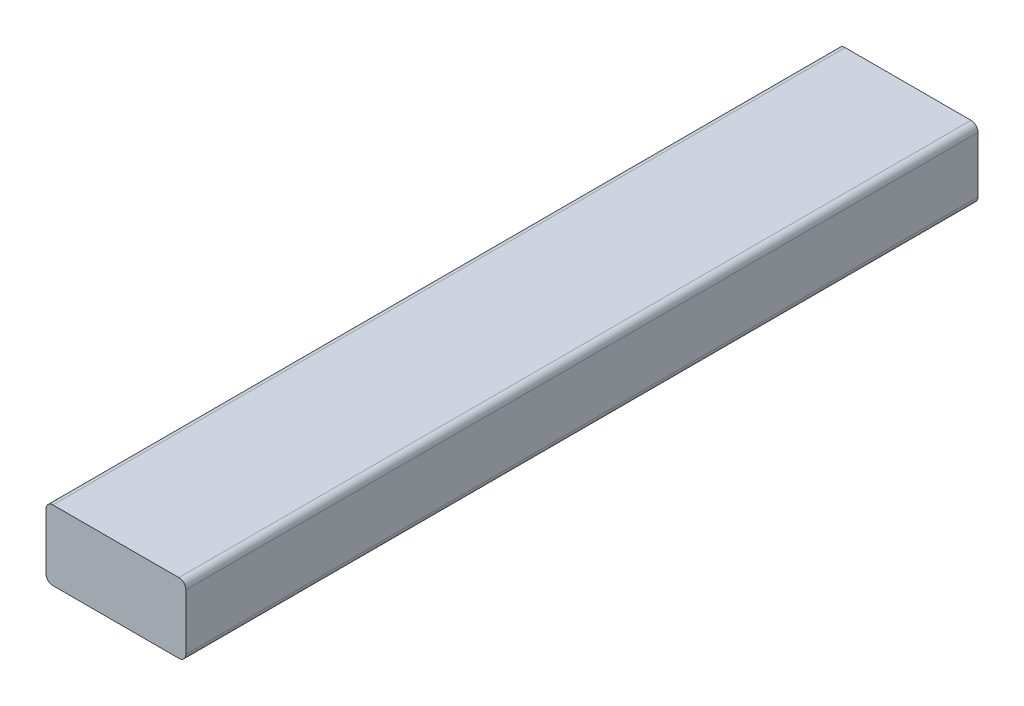
from build123d import *

# Parameters (mm, degrees)
SKETCH2_W           = 101.6
SKETCH2_H           = 50.8
BOSS_EXTRUDE1_DEPTH = 575.4
FILLET1_R           = 5.08


with BuildPart() as part:
    # Sketch2 → Boss-Extrude1 (new body)
    with BuildSketch(Plane(origin=(0, 0, 287.7), x_dir=(-1, 0, 0), z_dir=(0, 0, -1))):
        with Locations((-2663.5, 12.7)):
            Rectangle(SKETCH2_W, SKETCH2_H)
    extrude(amount=BOSS_EXTRUDE1_DEPTH)

    # Fillet1
    fillet1_edges = [part.edges().sort_by_distance(p)[0] for p in [
        (2714.3, 38.1, 0),
        (2612.7, 38.1, 0),
        (2612.7, -12.7, 0),
        (2714.3, -12.7, 0),
    ]]
    fillet(fillet1_edges, radius=FILLET1_R)


solid = part.part
